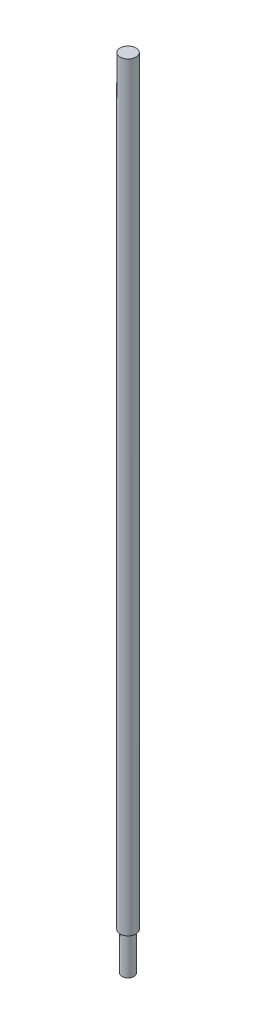
from build123d import *

# Parameters (mm, degrees)
AUFSATZ_LINEAR_START            = 218
SKIZZE3_R                       = 4
AUFSATZ_LINEAR_AUSTRAGEN1_DEPTH = 400
SKIZZE5_R                       = 4
SKIZZE5_R_2                     = 3
SCHNITT_LINEAR_AUSTRAGEN1_DEPTH = 19


with BuildPart() as part:
    # Skizze3 → Aufsatz-Linear austragen1 (new body)
    with BuildSketch(Plane(origin=(0, 0, 0), x_dir=(1, 0, 0), z_dir=(0, 1, 0)).offset(AUFSATZ_LINEAR_START)):
        Circle(SKIZZE3_R)
    extrude(amount=AUFSATZ_LINEAR_AUSTRAGEN1_DEPTH)

    # Skizze5 → Schnitt-Linear austragen1 (cut)
    with BuildSketch(Plane.XZ.offset(-218)):
        Circle(SKIZZE5_R)
        Circle(SKIZZE5_R_2, mode=Mode.SUBTRACT)
    extrude(amount=-SCHNITT_LINEAR_AUSTRAGEN1_DEPTH, mode=Mode.SUBTRACT)


solid = part.part
